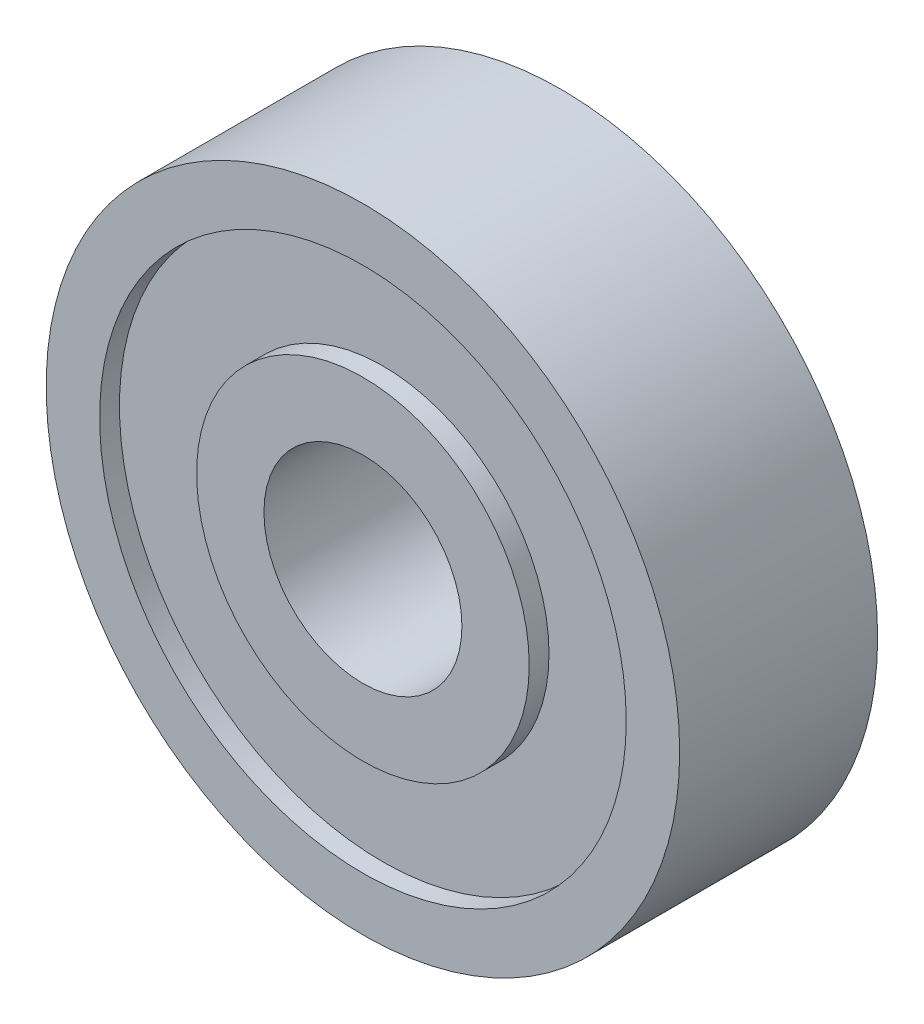
from build123d import *

# Parameters (mm, degrees)
SKETCH_1_R          = 8
EXTRUDE_1_DEPTH     = 2.5
SKETCH_2_R          = 2.5
CUT_EXTRUDE_1_DEPTH = 6
SKETCH_3_R          = 6.65
SKETCH_3_R_2        = 4.2
CUT_EXTRUDE_2_DEPTH = 0.5


with BuildPart() as part:
    # 草圖1 → 填料-伸長1 (new body, symmetric)
    with BuildSketch(Plane.XY):
        Circle(SKETCH_1_R)
    extrude(amount=EXTRUDE_1_DEPTH, both=True)

    # 草圖2 → 除料-伸長1 (cut, through all)
    with BuildSketch(Plane.XY.offset(2.5)):
        Circle(SKETCH_2_R)
    extrude(amount=-CUT_EXTRUDE_1_DEPTH, mode=Mode.SUBTRACT)

    # 草圖3 → 除料-伸長2 (cut)
    with BuildSketch(Plane.XY.offset(2.5)):
        Circle(SKETCH_3_R)
        Circle(SKETCH_3_R_2, mode=Mode.SUBTRACT)
    cut_extrude_2 = extrude(amount=-CUT_EXTRUDE_2_DEPTH, mode=Mode.SUBTRACT)

    # 鏡射1: 除料-伸長2 across plane
    add(cut_extrude_2.mirror(Plane.XY), mode=Mode.SUBTRACT)


solid = part.part
